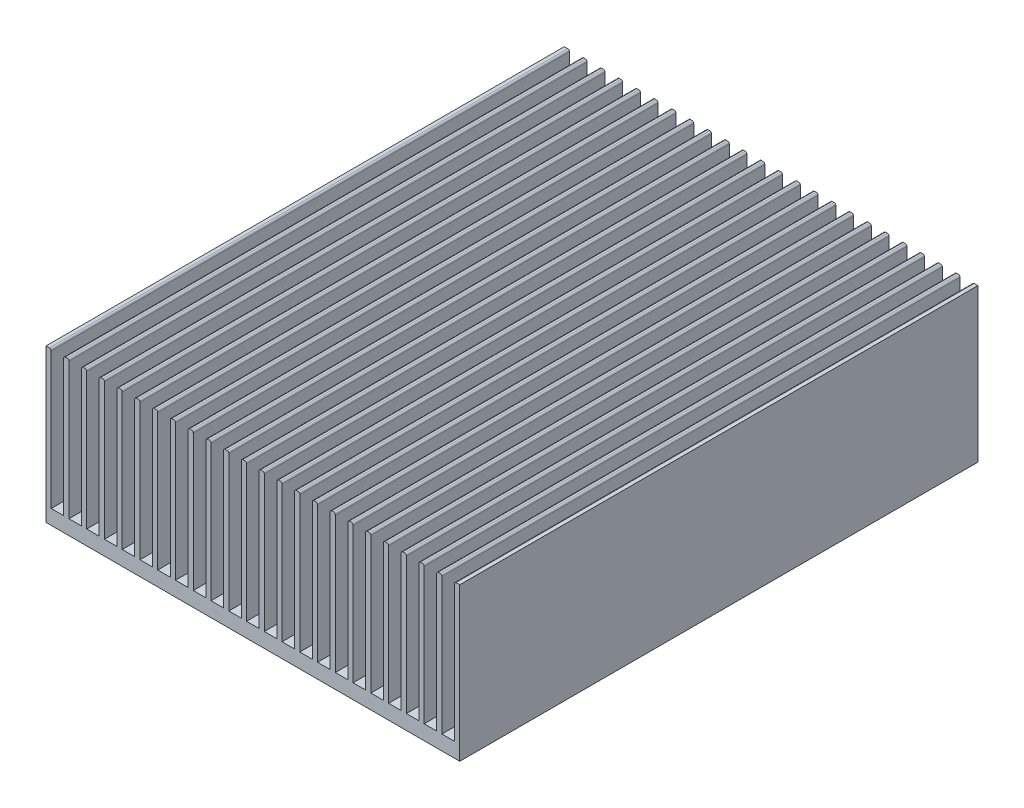
from build123d import *

# Parameters (mm, degrees)
SKETCH1_W              = 121.666
SKETCH1_H              = 44.958
EXTRUDE1_DEPTH         = 152.4
SKETCH2_W              = 3.683
SKETCH2_H              = 43.292875233
EXTRUDE2_DEPTH         = 152.4
FILLET1_R              = 0.508
LPATTERN1_COUNT        = 23
LPATTERN1_PITCH        = 5.22224
FILLET1_OF_LPATTERN1_R = 0.508
SKETCH4_R              = 1.5875
EXTRUDE3_DEPTH         = 3.81
SKETCH5_R              = 1.5875
EXTRUDE4_DEPTH         = 3.81
SKETCH6_R              = 1.778
EXTRUDE5_DEPTH         = 3.81


with BuildPart() as part:
    # Sketch1 → Extrude1 (new body)
    with BuildSketch(Plane.XY):
        with Locations((60.833, 22.479)):
            Rectangle(SKETCH1_W, SKETCH1_H)
    extrude(amount=-EXTRUDE1_DEPTH)

    # Sketch2 → Extrude2 (cut)
    with BuildSketch(Plane.XY):
        with Locations((3.3655, 25.964437616)):
            Rectangle(SKETCH2_W, SKETCH2_H)
    extrude2 = extrude(amount=-EXTRUDE2_DEPTH, mode=Mode.SUBTRACT)

    # Fillet1
    fillet1_edges = [part.edges().sort_by_distance(p)[0] for p in [
        (1.524, 44.958, -76.2),
        (5.207, 44.958, -76.2),
    ]]
    fillet(fillet1_edges, radius=FILLET1_R)

    # LPattern1: Extrude2 ×23
    with Locations(*[(i * LPATTERN1_PITCH, 0, 0) for i in range(1, LPATTERN1_COUNT)]):
        add(extrude2, mode=Mode.SUBTRACT)

    # Fillet1 of LPattern1
    fillet1_of_lpattern1_edges = [part.edges().sort_by_distance(p)[0] for p in [
        (6.74624, 44.958, -76.2),
        (10.42924, 44.958, -76.2),
        (11.96848, 44.958, -76.2),
        (15.65148, 44.958, -76.2),
        (17.19072, 44.958, -76.2),
        (20.87372, 44.958, -76.2),
        (22.41296, 44.958, -76.2),
        (26.09596, 44.958, -76.2),
        (27.6352, 44.958, -76.2),
        (31.3182, 44.958, -76.2),
        (32.85744, 44.958, -76.2),
        (36.54044, 44.958, -76.2),
        (38.07968, 44.958, -76.2),
        (41.76268, 44.958, -76.2),
        (43.30192, 44.958, -76.2),
        (46.98492, 44.958, -76.2),
        (48.52416, 44.958, -76.2),
        (52.20716, 44.958, -76.2),
        (53.7464, 44.958, -76.2),
        (57.4294, 44.958, -76.2),
        (58.96864, 44.958, -76.2),
        (62.65164, 44.958, -76.2),
        (64.19088, 44.958, -76.2),
        (67.87388, 44.958, -76.2),
        (69.41312, 44.958, -76.2),
        (73.09612, 44.958, -76.2),
        (74.63536, 44.958, -76.2),
        (78.31836, 44.958, -76.2),
        (79.8576, 44.958, -76.2),
        (83.5406, 44.958, -76.2),
        (85.07984, 44.958, -76.2),
        (88.76284, 44.958, -76.2),
        (90.30208, 44.958, -76.2),
        (93.98508, 44.958, -76.2),
        (95.52432, 44.958, -76.2),
        (99.20732, 44.958, -76.2),
        (100.74656, 44.958, -76.2),
        (104.42956, 44.958, -76.2),
        (105.9688, 44.958, -76.2),
        (109.6518, 44.958, -76.2),
        (111.19104, 44.958, -76.2),
        (114.87404, 44.958, -76.2),
        (116.41328, 44.958, -76.2),
        (120.09628, 44.958, -76.2),
    ]]
    fillet(fillet1_of_lpattern1_edges, radius=FILLET1_OF_LPATTERN1_R)

    # Sketch4 → Extrude3 (cut)
    with BuildSketch(Plane.XZ):
        with Locations(Location((34.671, -43.18, 0), (0, 0, 270))):  # turned: the seam where the file's is
            Circle(SKETCH4_R)
        with Locations(Location((88.011, -109.22, 0), (0, 0, 270))):  # turned: the seam where the file's is
            Circle(SKETCH4_R)
    extrude(amount=-EXTRUDE3_DEPTH, mode=Mode.SUBTRACT)

    # Sketch5 → Extrude4 (cut)
    with BuildSketch(Plane.XZ):
        with Locations(Location((25.908, -43.18, 0), (0, 0, 270))):  # turned: the seam where the file's is
            Circle(SKETCH5_R)
        with Locations(Location((95.758, -109.22, 0), (0, 0, 270))):  # turned: the seam where the file's is
            Circle(SKETCH5_R)
    extrude(amount=-EXTRUDE4_DEPTH, mode=Mode.SUBTRACT)

    # Sketch6 → Extrude5 (cut)
    with BuildSketch(Plane.XZ):
        with Locations(Location((25.908, -13.081, 0), (0, 0, 270))):  # turned: the seam where the file's is
            Circle(SKETCH6_R)
        with Locations(Location((95.758, -13.081, 0), (0, 0, 270))):  # turned: the seam where the file's is
            Circle(SKETCH6_R)
        with Locations(Location((25.908, -63.9318, 0), (0, 0, 270))):  # turned: the seam where the file's is
            Circle(SKETCH6_R)
        with Locations(Location((95.758, -63.9318, 0), (0, 0, 270))):  # turned: the seam where the file's is
            Circle(SKETCH6_R)
        with Locations(Location((25.908, -140.081, 0), (0, 0, 270))):  # turned: the seam where the file's is
            Circle(SKETCH6_R)
        with Locations(Location((95.758, -140.081, 0), (0, 0, 270))):  # turned: the seam where the file's is
            Circle(SKETCH6_R)
    extrude(amount=-EXTRUDE5_DEPTH, mode=Mode.SUBTRACT)


solid = part.part
